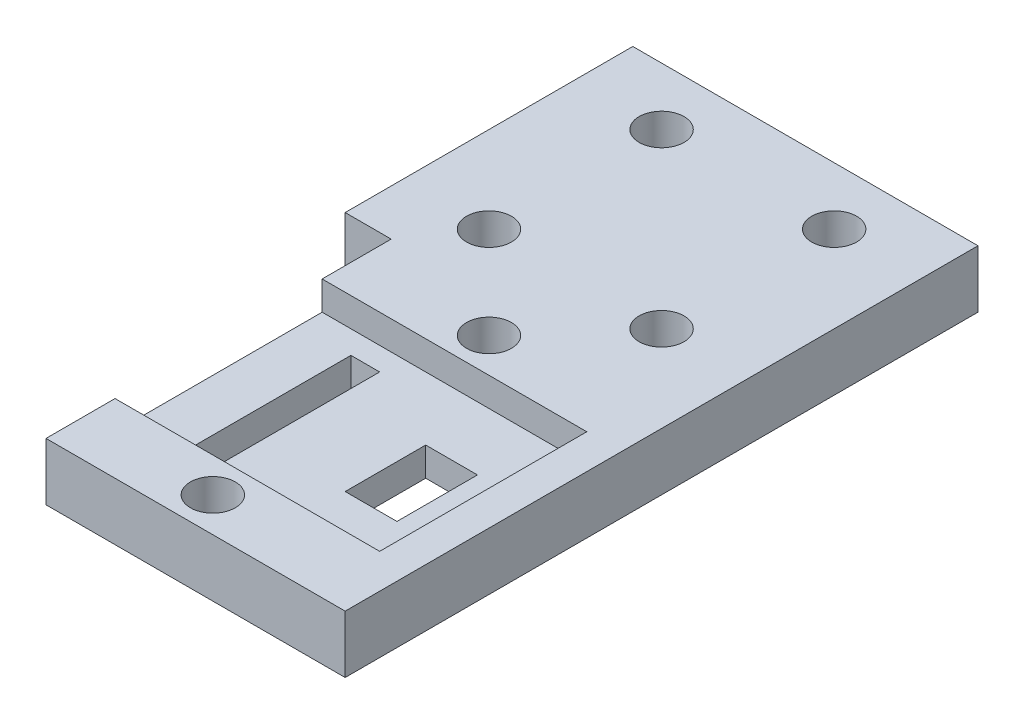
from build123d import *

# Parameters (mm, degrees)
ESQUISSE1_W             = 30
ESQUISSE1_H             = 60
BOSS_EXTRU_1_DEPTH      = 5
D_GAGEMENT_M3_51_D      = 3.9
ESQUISSE19_W            = 26
ESQUISSE19_H            = 5
ENL_V_MAT_EXTRU_5_DEPTH = 6
D_GAGEMENT_M3_53_D      = 3.9
D_GAGEMENT_M3_53_DEPTH  = 5
D_GAGEMENT_M3_53_TIP    = 1.171678207
ESQUISSE22_W            = 23
ESQUISSE22_H            = 18
ENL_V_MAT_EXTRU_6_DEPTH = 2.5
ESQUISSE23_W            = 2.5
ESQUISSE23_H            = 14
ESQUISSE23_W_2          = 4.5
ESQUISSE23_H_2          = 7
ENL_V_MAT_EXTRU_7_DEPTH = 3.5


with BuildPart() as part:
    # Esquisse1 → Boss.-Extru.1 (new body)
    with BuildSketch(Plane(origin=(0, 0, 0), x_dir=(1, 0, 0), z_dir=(0, 1, 0))):
        with Locations((15, 30)):
            Rectangle(ESQUISSE1_W, ESQUISSE1_H)
    extrude(amount=BOSS_EXTRU_1_DEPTH)

    # Dégagement M3.51 (through all)
    with Locations(Plane(origin=(0, 5, 0), x_dir=(1, 0, 0), z_dir=(0, 1, 0))):
        with Locations((7.5, 40), (22.5, 40), (22.5, 55), (7.5, 55)):
            Hole(D_GAGEMENT_M3_51_D / 2)

    # Esquisse19 → Enlèv. mat.-Extru.5 (cut, through all)
    with BuildSketch(Plane(origin=(0, 5, 0), x_dir=(1, 0, 0), z_dir=(0, 1, 0))):
        Polygon((4, 5), (4, 35), (0, 35), (0, 0), (4, 0), align=None)
        with Locations((17, 2.5)):
            Rectangle(ESQUISSE19_W, ESQUISSE19_H)
    extrude(amount=-ENL_V_MAT_EXTRU_5_DEPTH, mode=Mode.SUBTRACT)

    # Dégagement M3.53
    with Locations(Plane(origin=(0, 5, 0), x_dir=(1, 0, 0), z_dir=(0, 1, 0))):
        with Locations((15.5, 32), (15.5, 8)):
            Hole(D_GAGEMENT_M3_53_D / 2, depth=D_GAGEMENT_M3_53_DEPTH)
            with Locations((0, 0, -(D_GAGEMENT_M3_53_DEPTH + D_GAGEMENT_M3_53_TIP / 2))):  # 118° drill point
                Cone(0, D_GAGEMENT_M3_53_D / 2, D_GAGEMENT_M3_53_TIP, mode=Mode.SUBTRACT)

    # Esquisse22 → Enlèv. mat.-Extru.6 (cut)
    with BuildSketch(Plane(origin=(0, 5, 0), x_dir=(1, 0, 0), z_dir=(0, 1, 0))):
        with Locations((15.5, 20)):
            Rectangle(ESQUISSE22_W, ESQUISSE22_H)
    extrude(amount=-ENL_V_MAT_EXTRU_6_DEPTH, mode=Mode.SUBTRACT)

    # Esquisse23 → Enlèv. mat.-Extru.7 (cut, through all)
    with BuildSketch(Plane(origin=(0, 2.5, 0), x_dir=(1, 0, 0), z_dir=(0, 1, 0))):
        with Locations((9.75, 20)):
            Rectangle(ESQUISSE23_W, ESQUISSE23_H)
        with Locations((20.75, 20)):
            Rectangle(ESQUISSE23_W_2, ESQUISSE23_H_2)
    extrude(amount=-ENL_V_MAT_EXTRU_7_DEPTH, mode=Mode.SUBTRACT)


solid = part.part
